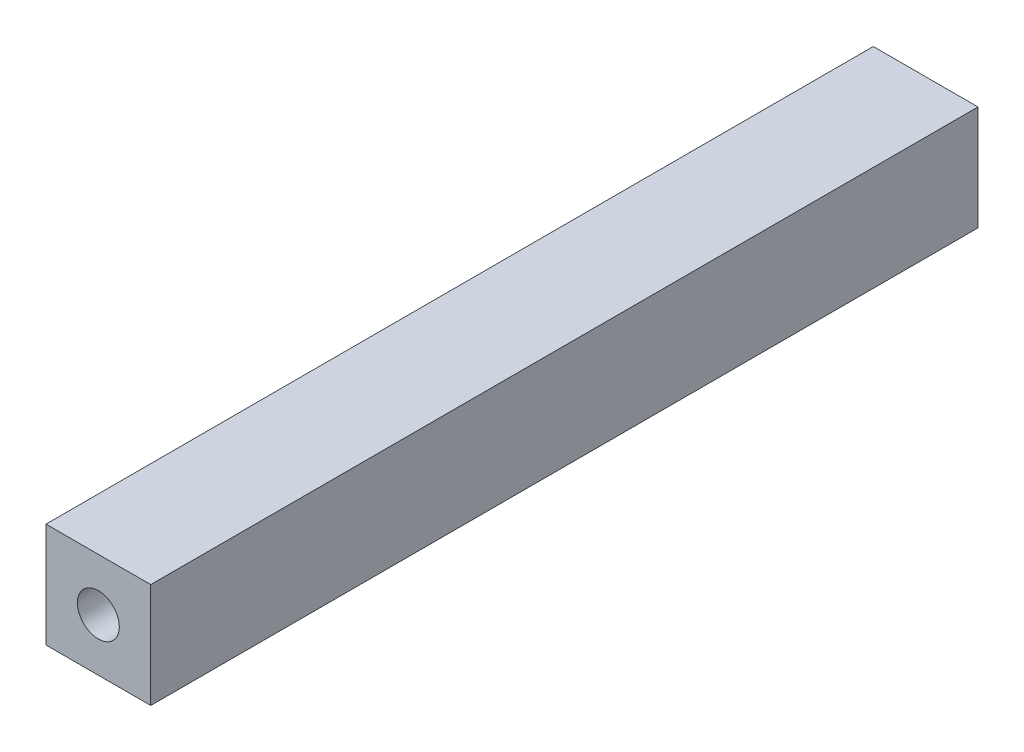
from build123d import *

# Parameters (mm, degrees)
SKETCH1_W           = 10
SKETCH1_H           = 10
SKETCH1_R           = 2
BOSS_EXTRUDE1_DEPTH = 79


with BuildPart() as part:
    # Sketch1 → Boss-Extrude1 (new body)
    with BuildSketch(Plane.XY):
        Rectangle(SKETCH1_W, SKETCH1_H)
        Circle(SKETCH1_R, mode=Mode.SUBTRACT)
    extrude(amount=BOSS_EXTRUDE1_DEPTH)


solid = part.part
